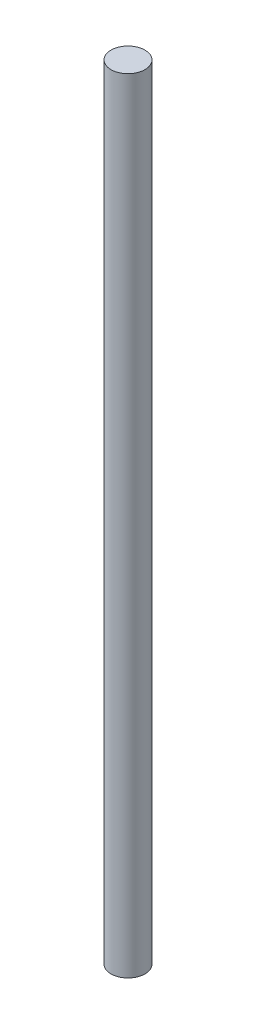
from build123d import *

# Parameters (mm, degrees)
SKETCH1_R           = 1.3
BOSS_EXTRUDE1_DEPTH = 60


with BuildPart() as part:
    # Sketch1 → Boss-Extrude1 (new body)
    with BuildSketch(Plane(origin=(0, 0, 0), x_dir=(1, 0, 0), z_dir=(0, 1, 0))):
        Circle(SKETCH1_R)
    extrude(amount=BOSS_EXTRUDE1_DEPTH)


solid = part.part
